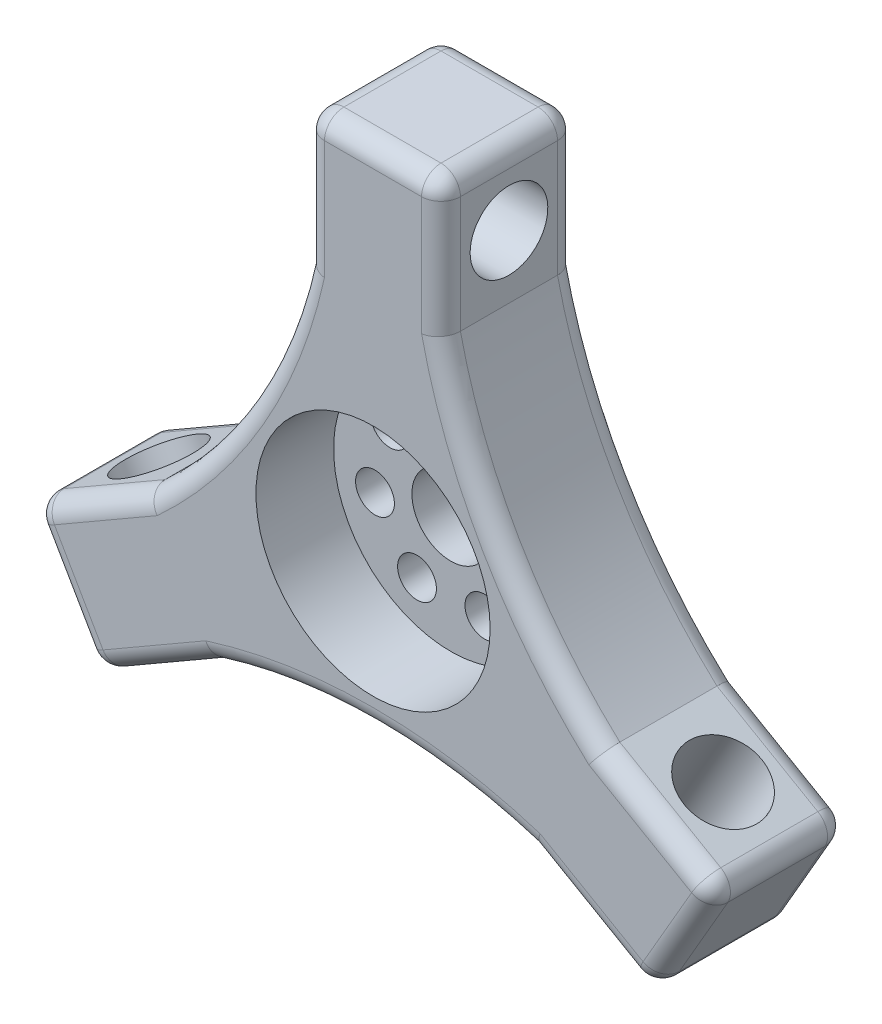
from build123d import *

# Parameters (mm, degrees)
SKETCH2_R           = 4
BOSS_EXTRUDE1_DEPTH = 14
SKETCH7_R           = 12.060749
CUT_EXTRUDE4_DEPTH  = 8
SKETCH8_R           = 2
CUT_EXTRUDE5_DEPTH  = 8
FILLET2_R           = 2
CUT_EXTRUDE6_REACH  = 53.745
SKETCH10_R          = 4
FILLET4_R           = 2
CIRPATTERN1_COUNT   = 3


with BuildPart() as part:
    # Sketch2 → Boss-Extrude1 (new body)
    with BuildSketch(Plane.XY):
        with BuildLine():
            Line((-7, 23), (-7, 37))
            Line((-7, 37), (7, 37))
            Line((7, 37), (7, 23))
            ThreePointArc((7, 23), (13.037466, 7.527184), (23.418584, -5.437822))
            Line((23.418584, -5.437822), (35.54294, -12.437822))
            Line((35.54294, -12.437822), (28.54294, -24.562178))
            Line((28.54294, -24.562178), (16.418584, -17.562178))
            ThreePointArc((16.418584, -17.562178), (0, -15.054369), (-16.418584, -17.562178))
            Line((-16.418584, -17.562178), (-28.54294, -24.562178))
            Line((-28.54294, -24.562178), (-35.54294, -12.437822))
            Line((-35.54294, -12.437822), (-23.418584, -5.437822))
            ThreePointArc((-23.418584, -5.437822), (-13.037466, 7.527184), (-7, 23))
        make_face()
        Circle(SKETCH2_R, mode=Mode.SUBTRACT)
    extrude(amount=BOSS_EXTRUDE1_DEPTH)

    # Sketch7 → Cut-Extrude4 (cut)
    with BuildSketch(Plane.XY.offset(14)):
        Circle(SKETCH7_R)
    extrude(amount=-CUT_EXTRUDE4_DEPTH, mode=Mode.SUBTRACT)

    # Sketch8 → Cut-Extrude5 (cut)
    with BuildSketch(Plane.XY.offset(6)):
        with Locations((0, 8)):
            Circle(SKETCH8_R)
        with Locations((6.254652, 4.987918)):
            Circle(SKETCH8_R)
        with Locations((7.799423, -1.780167)):
            Circle(SKETCH8_R)
        with Locations((3.47107, -7.207751)):
            Circle(SKETCH8_R)
        with Locations((-3.47107, -7.207751)):
            Circle(SKETCH8_R)
        with Locations((-7.799423, -1.780167)):
            Circle(SKETCH8_R)
        with Locations((-6.254652, 4.987918)):
            Circle(SKETCH8_R)
    extrude(amount=-CUT_EXTRUDE5_DEPTH, mode=Mode.SUBTRACT)

    # Fillet2
    fillet2_edges = [part.edges().sort_by_distance(p)[0] for p in [
        (32.04294, -18.5, 0),
        (-32.04294, -18.5, 0),
        (0, 37, 0),
        (-32.04294, -18.5, 14),
        (32.04294, -18.5, 14),
        (0, 37, 14),
    ]]
    fillet(fillet2_edges, radius=FILLET2_R)

    # Sketch10 → Cut-Extrude6 (cut, up to next)
    with BuildSketch(Plane(origin=(3.5, 6.062178, 0), x_dir=(0.866025403784439, -0.4999999999999995, 0), z_dir=(0.49999999999999944, 0.8660254037844389, 0)), mode=Mode.PRIVATE) as cut_extrude6_sk1:
        with Locations(Location((29.5, -7, 0), (0, 0, 180))):
            Circle(SKETCH10_R)
    cut_extrude6_tool1 = extrude(cut_extrude6_sk1.sketch, amount=-CUT_EXTRUDE6_REACH, mode=Mode.PRIVATE) & part.part
    cut_extrude6 = cut_extrude6_tool1.solids().sort_by_distance((29.047749, -8.687822, 7))[0]
    add(cut_extrude6, mode=Mode.SUBTRACT)

    # Fillet4
    fillet4_edges = [part.edges().sort_by_distance(p)[0] for p in [
        (7, 29, 0),
        (13.037466, 7.527184, 0),
        (-13.037466, 7.527184, 14),
        (21.614737, -20.562178, 0),
        (0, -15.054369, 0),
        (-28.614737, -8.437822, 0),
        (-13.037466, 7.527184, 0),
        (-28.614737, -8.437822, 14),
        (0, -15.054369, 14),
        (21.614737, -20.562178, 14),
        (13.037466, 7.527184, 14),
        (7, 29, 14),
        (-7, 37, 7),
        (7, 37, 7),
        (-7, 29, 0),
        (-7, 29, 14),
        (-7, 36.414214, 13.414214),
        (-7, 36.414214, 0.585786),
        (28.614737, -8.437822, 0),
        (-21.614737, -20.562178, 0),
        (7, 36.414214, 13.414214),
        (7, 36.414214, 0.585786),
        (-21.614737, -20.562178, 14),
        (28.614737, -8.437822, 14),
        (-28.54294, -24.562178, 7),
        (-35.54294, -12.437822, 7),
        (-28.035634, -24.269285, 13.414214),
        (-28.035634, -24.269285, 0.585786),
        (-35.035634, -12.144929, 13.414214),
        (-35.035634, -12.144929, 0.585786),
        (35.54294, -12.437822, 7),
        (28.54294, -24.562178, 7),
        (35.035634, -12.144929, 13.414214),
        (35.035634, -12.144929, 0.585786),
        (28.035634, -24.269285, 13.414214),
        (28.035634, -24.269285, 0.585786),
    ]]
    fillet(fillet4_edges, radius=FILLET4_R)

    # CirPattern1: Cut-Extrude6 ×3 about axis
    cirpattern1_axis = Axis((0, 0, 6), (0, 0, 1))
    for i in range(1, CIRPATTERN1_COUNT):
        add(cut_extrude6.rotate(cirpattern1_axis, i * 360 / CIRPATTERN1_COUNT), mode=Mode.SUBTRACT)


solid = part.part
